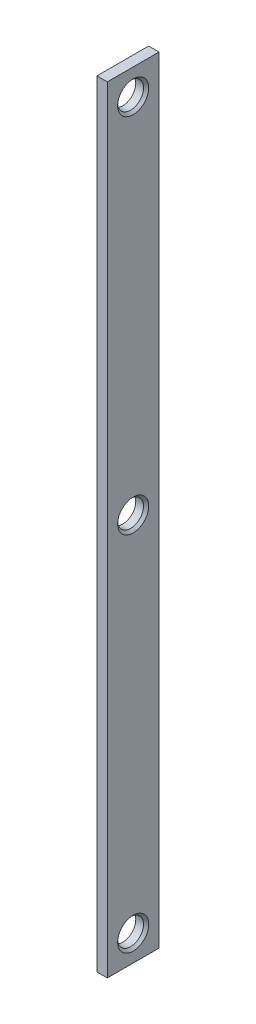
from build123d import *

# Parameters (mm, degrees)
SKETCH_1_W          = 4
SKETCH_1_H          = 20
EXTRUDE_1_DEPTH     = 300
SKETCH_2_R          = 5
CUT_EXTRUDE_1_DEPTH = 5
CHAMFER_1_SIZE      = 1


with BuildPart() as part:
    # Эскиз1 → Бобышка-Вытянуть1 (new body)
    with BuildSketch(Plane(origin=(0, 0, 0), x_dir=(1, 0, 0), z_dir=(0, 1, 0))):
        Rectangle(SKETCH_1_W, SKETCH_1_H)
    extrude(amount=EXTRUDE_1_DEPTH)

    # Эскиз2 → Вырез-Вытянуть1 (cut, through all)
    with BuildSketch(Plane(origin=(2, 0, 0), x_dir=(0, 0, -1), z_dir=(1, 0, 0))):
        with Locations((0, 290)):
            Circle(SKETCH_2_R)
        with Locations((0, 150)):
            Circle(SKETCH_2_R)
        with Locations((0, 10)):
            Circle(SKETCH_2_R)
    extrude(amount=-CUT_EXTRUDE_1_DEPTH, mode=Mode.SUBTRACT)

    # Фаска1
    chamfer_1_edges = [part.edges().sort_by_distance(p)[0] for p in [
        (2, 290, 5),
        (2, 150, 5),
        (2, 10, 5),
    ]]
    chamfer(chamfer_1_edges, length=CHAMFER_1_SIZE)


solid = part.part
